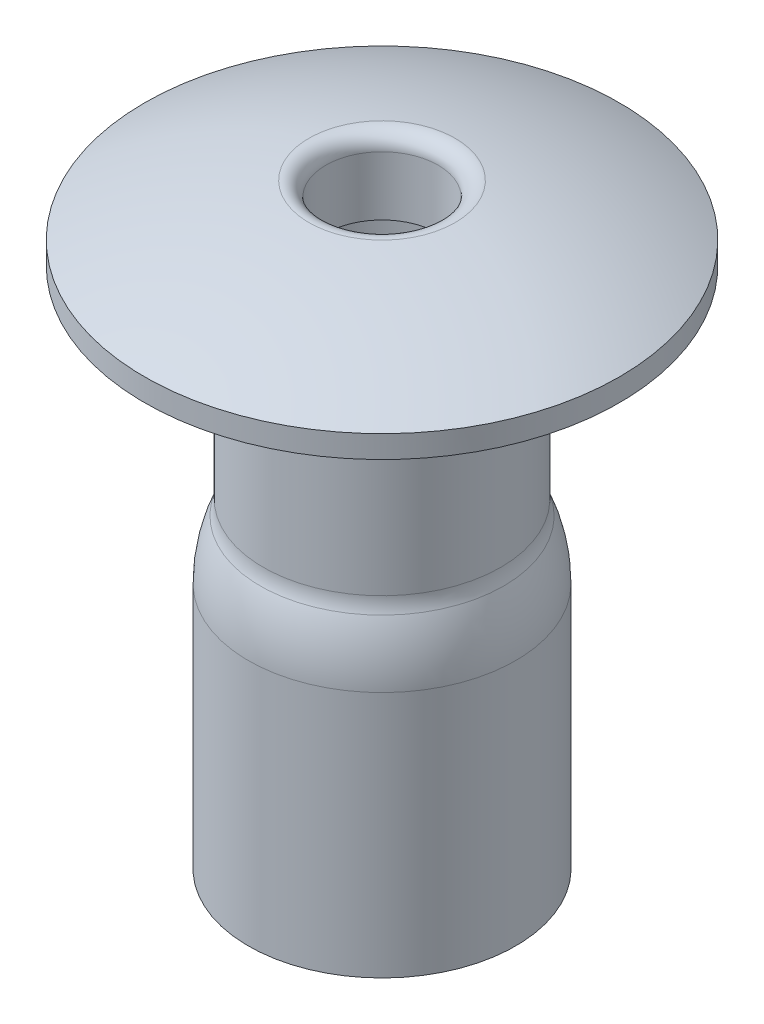
from build123d import *

# Parameters (mm, degrees)
FILLET1_R = 0.2


with BuildPart() as part:
    # Sketch1 → Revolve1 (revolve)
    with BuildSketch(Plane.XY):
        with BuildLine():
            Line((1.5875, -3.679795897), (1.5875, -6.985))
            Line((1.5875, -6.985), (1.7875, -6.985))
            Line((1.7875, -6.985), (1.7875, -3.679795897))
            ThreePointArc((1.7875, -3.679795897), (1.747091794, -3.279795897), (1.6275, -2.895959179))
            ThreePointArc((1.6275, -2.895959179), (1.597602051, -2.8), (1.5875, -2.7))
            Line((1.5875, -2.7), (1.5875, 0))
            Line((1.5875, 0), (3.175, 0))
            Line((3.175, 0), (3.175, 0.3))
            ThreePointArc((3.175, 0.3), (1.994886024, 0.767687303), (0.75, 1.016))
            Line((0.75, 1.016), (0.75, 0))
            Line((0.75, 0), (1.3875, 0))
            Line((1.3875, 0), (1.3875, -2.7))
            ThreePointArc((1.3875, -2.7), (1.401642872, -2.84), (1.4435, -2.974342851))
            ThreePointArc((1.4435, -2.974342851), (1.551132615, -3.319795897), (1.5875, -3.679795897))
        make_face()
    revolve(axis=Axis((0, 1.016, 0), (0, -1, 0)))

    # Fillet1
    fillet1_edges = [part.edges().sort_by_distance(p)[0] for p in [
        (-0.75, 1.016, 0),
    ]]
    fillet(fillet1_edges, radius=FILLET1_R)


solid = part.part
